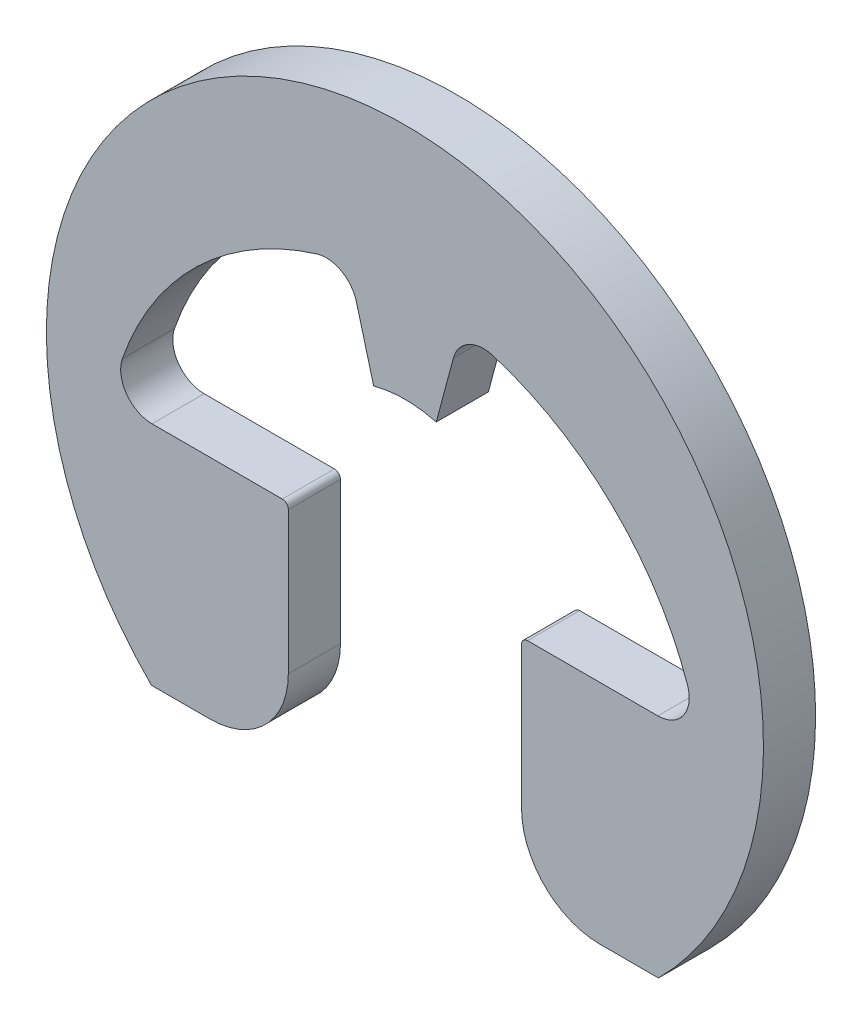
from build123d import *

# Parameters (mm, degrees)
BODY_DEPTH = 0.635


with BuildPart() as part:
    # BodySke → Body (new body)
    with BuildSketch(Plane.XY):
        with BuildLine():
            Line((3.08825445, -3.08825445), (2.375594962, -3.08825445))
            ThreePointArc((2.375594962, -3.08825445), (1.700235197, -2.808511276), (1.420492024, -2.133151512))
            Line((1.420492024, -2.133151512), (1.420492024, -0.400356828))
            ThreePointArc((1.420492024, -0.400356828), (1.442066538, -0.348271343), (1.494152024, -0.326696828))
            Line((1.494152024, -0.326696828), (3.080912536, -0.326696828))
            ThreePointArc((3.080912536, -0.326696828), (3.392132841, -0.166234942), (3.441920608, 0.180358874))
            ThreePointArc((3.441920608, 0.180358874), (2.530552339, 1.608327553), (1.071838527, 2.46962929))
            ThreePointArc((1.071838527, 2.46962929), (0.774531372, 2.438826913), (0.590394611, 2.203382686))
            Line((0.590394611, 2.203382686), (0.381292217, 1.423001927))
            ThreePointArc((0.381292217, 1.423001927), (0, 1.4732), (-0.381292217, 1.423001927))
            Line((-0.381292217, 1.423001927), (-0.590394611, 2.203382686))
            ThreePointArc((-0.590394611, 2.203382686), (-0.774531372, 2.438826913), (-1.071838527, 2.46962929))
            ThreePointArc((-1.071838527, 2.46962929), (-2.530552339, 1.608327553), (-3.441920608, 0.180358874))
            ThreePointArc((-3.441920608, 0.180358874), (-3.392132841, -0.166234942), (-3.080912536, -0.326696828))
            Line((-3.080912536, -0.326696828), (-1.494152024, -0.326696828))
            ThreePointArc((-1.494152024, -0.326696828), (-1.442066538, -0.348271343), (-1.420492024, -0.400356828))
            Line((-1.420492024, -0.400356828), (-1.420492024, -2.133151512))
            ThreePointArc((-1.420492024, -2.133151512), (-1.700235197, -2.808511276), (-2.375594962, -3.08825445))
            Line((-2.375594962, -3.08825445), (-3.08825445, -3.08825445))
            ThreePointArc((-3.08825445, -3.08825445), (0, 4.367451327), (3.08825445, -3.08825445))
        make_face()
    extrude(amount=-BODY_DEPTH)


solid = part.part
